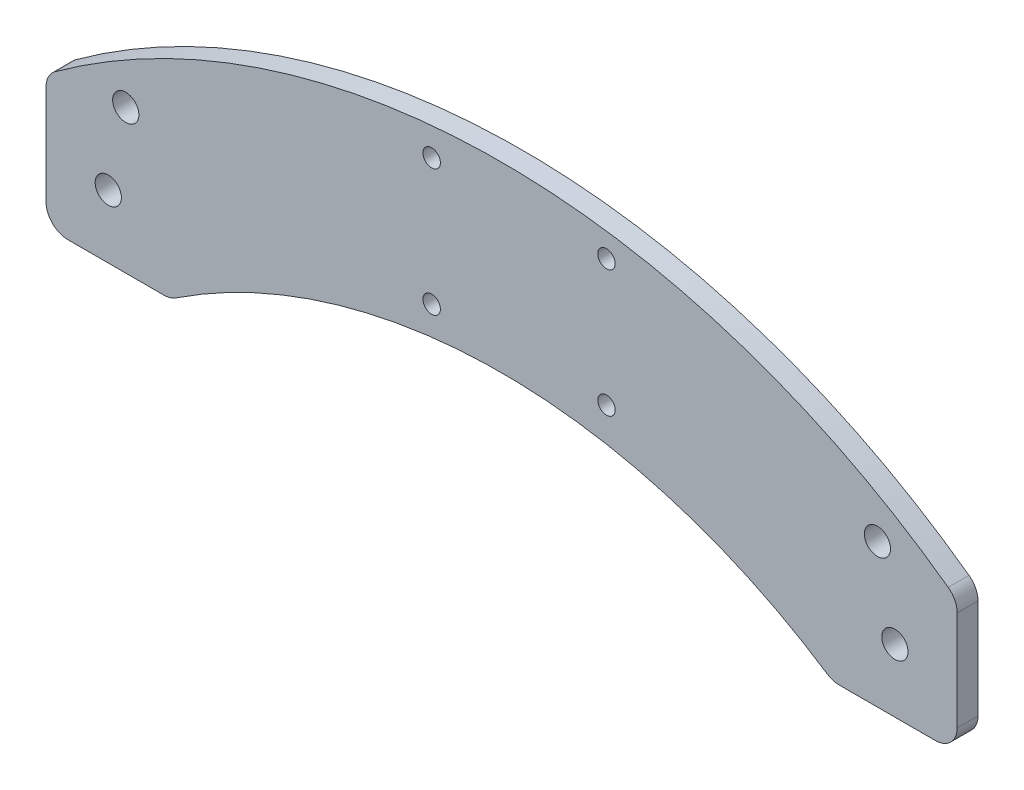
from build123d import *

# Parameters (mm, degrees)
SKETCH1_R           = 2
SKETCH1_R_2         = 3
BOSS_EXTRUDE1_DEPTH = 4.7625
SKETCH4_W           = 20
SKETCH4_H           = 20
CUT_EXTRUDE2_DEPTH  = 0.01


with BuildPart() as part:
    # Sketch1 → Boss-Extrude1 (new body)
    with BuildSketch(Plane.XY):
        with BuildLine():
            Line((-14.25, -9.45), (-14.25, 13.336101268))
            ThreePointArc((-14.25, 13.336101268), (-13.704321085, 15.607449693), (-12.186390533, 17.383027341))
            ThreePointArc((-12.186390533, 17.383027341), (90, 50.55), (192.186390533, 17.383027341))
            ThreePointArc((192.186390533, 17.383027341), (193.704321085, 15.607449693), (194.25, 13.336101268))
            Line((194.25, 13.336101268), (194.25, -9.45))
            ThreePointArc((194.25, -9.45), (192.785533906, -12.985533906), (189.25, -14.45))
            Line((189.25, -14.45), (167.269740757, -14.45))
            ThreePointArc((167.269740757, -14.45), (165.828788887, -14.237865674), (164.510107159, -13.619463083))
            ThreePointArc((164.510107159, -13.619463083), (90, 8.80503367), (15.489892841, -13.619463083))
            ThreePointArc((15.489892841, -13.619463083), (14.171211113, -14.237865674), (12.730259243, -14.45))
            Line((12.730259243, -14.45), (-9.25, -14.45))
            ThreePointArc((-9.25, -14.45), (-12.785533906, -12.985533906), (-14.25, -9.45))
        make_face()
        with Locations((74, 43.4)):
            Circle(SKETCH1_R, mode=Mode.SUBTRACT)
        with Locations((74, 14.4)):
            Circle(SKETCH1_R, mode=Mode.SUBTRACT)
        with Locations((114, 43.4)):
            Circle(SKETCH1_R, mode=Mode.SUBTRACT)
        with Locations((114, 14.4)):
            Circle(SKETCH1_R, mode=Mode.SUBTRACT)
        with Locations((180, 0)):
            Circle(SKETCH1_R_2, mode=Mode.SUBTRACT)
        Circle(SKETCH1_R_2, mode=Mode.SUBTRACT)
        with Locations((4, 18.4)):
            Circle(SKETCH1_R_2, mode=Mode.SUBTRACT)
        with Locations((176, 18.4)):
            Circle(SKETCH1_R_2, mode=Mode.SUBTRACT)
    extrude(amount=BOSS_EXTRUDE1_DEPTH)

    # Sketch4 → Cut-Extrude2 (cut)
    with BuildSketch(Plane.XY):
        Rectangle(SKETCH4_W, SKETCH4_H)
        with Locations((180, 0)):
            Rectangle(SKETCH4_W, SKETCH4_H)
    extrude(amount=CUT_EXTRUDE2_DEPTH, mode=Mode.SUBTRACT)


solid = part.part
